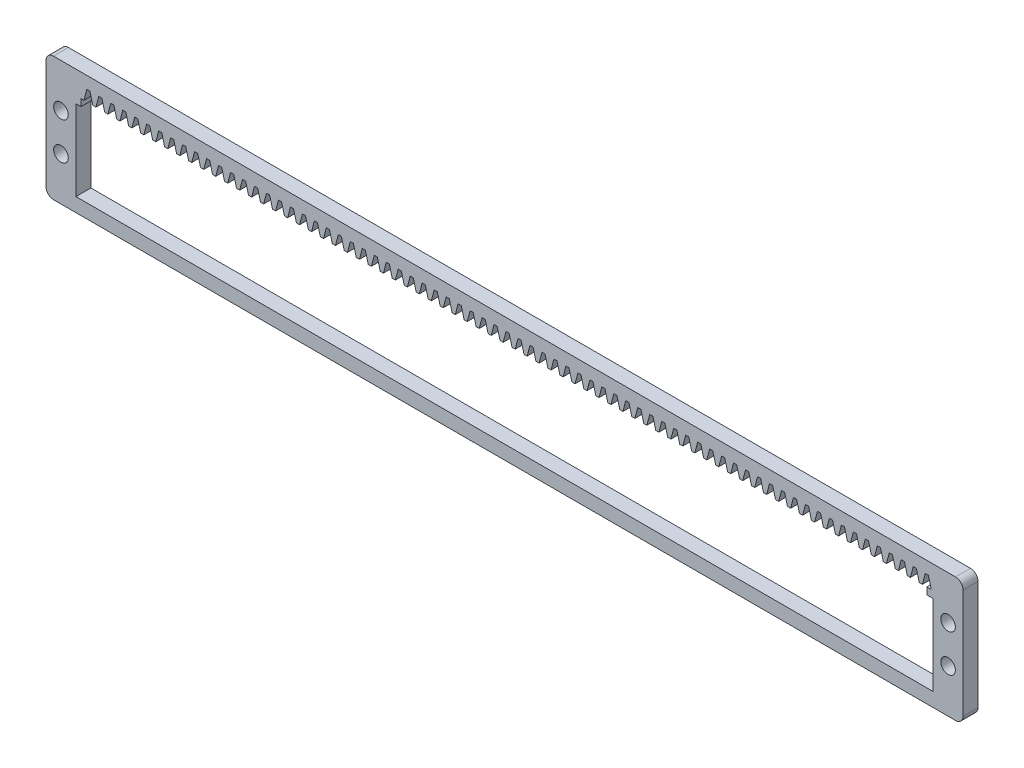
from build123d import *

# Parameters (mm, degrees)
BOSS_EXTRUDE1_DEPTH = 4
SKETCH2_W           = 229
SKETCH2_H           = 21.5
CUT_EXTRUDE1_DEPTH  = 5
SKETCH3_W           = 225.97
SKETCH3_H           = 1.85
CUT_EXTRUDE2_DEPTH  = 5
CUT_EXTRUDE4_DEPTH  = 5
LPATTERN1_COUNT     = 71
LPATTERN1_PITCH     = 3.2
SKETCH5_R           = 1.95
CUT_EXTRUDE5_DEPTH  = 10


with BuildPart() as part:
    # Sketch1 → Boss-Extrude1 (new body)
    with BuildSketch(Plane.XY):
        with BuildLine():
            Line((2, 0), (243, 0))
            ThreePointArc((243, 0), (244.414213562, -0.585786438), (245, -2))
            Line((245, -2), (245, -31.22))
            ThreePointArc((245, -31.22), (244.414213562, -32.634213562), (243, -33.22))
            Line((243, -33.22), (2, -33.22))
            ThreePointArc((2, -33.22), (0.585786438, -32.634213562), (0, -31.22))
            Line((0, -31.22), (0, -2))
            ThreePointArc((0, -2), (0.585786438, -0.585786438), (2, 0))
        make_face()
    extrude(amount=BOSS_EXTRUDE1_DEPTH)

    # Sketch2 → Cut-Extrude1 (cut, through all)
    with BuildSketch(Plane.XY.offset(4)):
        with Locations((122.5, -18.75)):
            Rectangle(SKETCH2_W, SKETCH2_H)
    extrude(amount=-CUT_EXTRUDE1_DEPTH, mode=Mode.SUBTRACT)

    # Sketch3 → Cut-Extrude2 (cut, through all)
    with BuildSketch(Plane.XY.offset(4)):
        with Locations((122.335, -7.075)):
            Rectangle(SKETCH3_W, SKETCH3_H)
    extrude(amount=-CUT_EXTRUDE2_DEPTH, mode=Mode.SUBTRACT)

    # Sketch4 → Cut-Extrude4 (cut, through all)
    with BuildSketch(Plane.XY.offset(4)):
        Polygon((235.735, -3.249176841), (236.5, -6.15), (234.14, -6.15), (234.905, -3.249176841), align=None)
    cut_extrude4 = extrude(amount=-CUT_EXTRUDE4_DEPTH, mode=Mode.SUBTRACT)

    # LPattern1: Cut-Extrude4 ×71
    with Locations(*[(-i * LPATTERN1_PITCH, 0, 0) for i in range(1, LPATTERN1_COUNT)]):
        add(cut_extrude4, mode=Mode.SUBTRACT)

    # Sketch5 → Cut-Extrude5 (cut)
    with BuildSketch(Plane.XY.offset(4)):
        with Locations((4, -11.61)):
            Circle(SKETCH5_R)
        with Locations((4, -21.61)):
            Circle(SKETCH5_R)
        with Locations((241, -11.61)):
            Circle(SKETCH5_R)
        with Locations((241, -21.61)):
            Circle(SKETCH5_R)
    extrude(amount=-CUT_EXTRUDE5_DEPTH, mode=Mode.SUBTRACT)


solid = part.part
